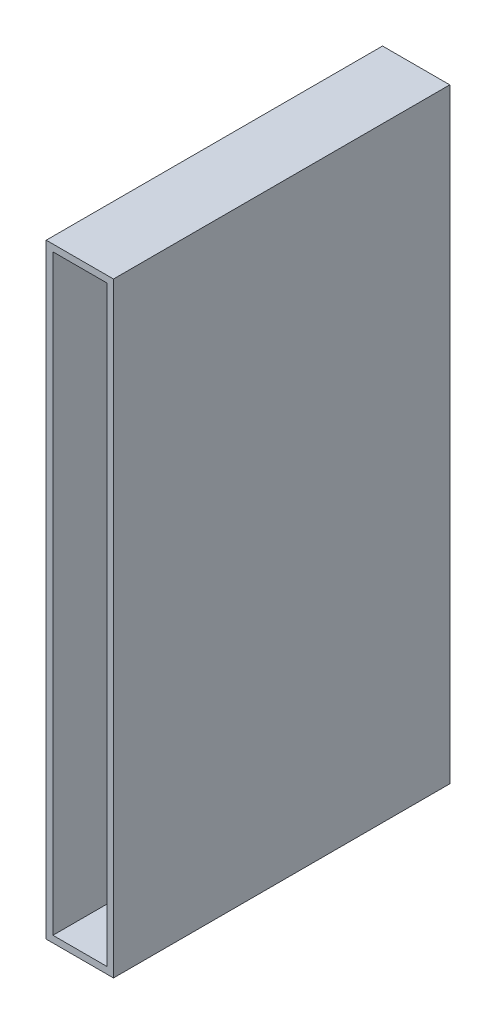
from build123d import *

# Parameters (mm, degrees)
ESQUISSE1_W        = 20
ESQUISSE1_H        = 180
ESQUISSE1_W_2      = 16
ESQUISSE1_H_2      = 176
BOSS_EXTRU_2_DEPTH = 100


with BuildPart() as part:
    # Esquisse1 → Boss.-Extru.2 (new body)
    with BuildSketch(Plane.XY):
        with Locations((10, 90)):
            Rectangle(ESQUISSE1_W, ESQUISSE1_H)
        with Locations((10, 90)):
            Rectangle(ESQUISSE1_W_2, ESQUISSE1_H_2, mode=Mode.SUBTRACT)
    extrude(amount=BOSS_EXTRU_2_DEPTH)


solid = part.part
